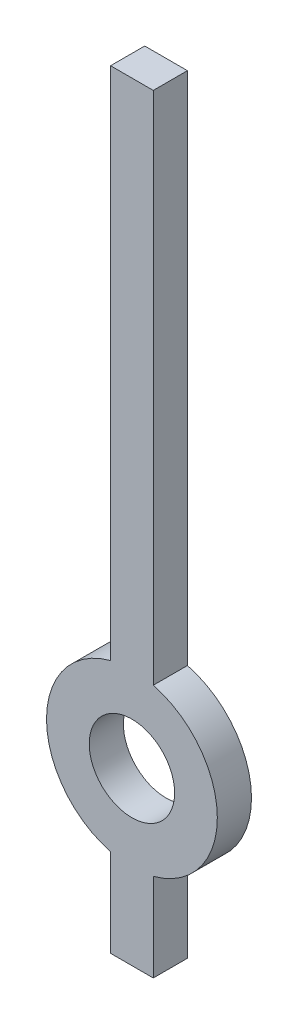
from build123d import *

# Parameters (mm, degrees)
CROQUIS1_R              = 0.25
SALIENTE_EXTRUIR1_DEPTH = 0.2


with BuildPart() as part:
    # Croquis1 → Saliente-Extruir1 (new body)
    with BuildSketch(Plane.XY):
        with BuildLine():
            Line((-0.125, -1), (-0.125, -0.484122918))
            ThreePointArc((-0.125, -0.484122918), (-0.5, 0), (-0.125, 0.484122918))
            Line((-0.125, 0.484122918), (-0.125, 3.5))
            Line((-0.125, 3.5), (0.125, 3.5))
            Line((0.125, 3.5), (0.125, 0.484122918))
            ThreePointArc((0.125, 0.484122918), (0.5, 0), (0.125, -0.484122918))
            Line((0.125, -0.484122918), (0.125, -1))
            Line((0.125, -1), (-0.125, -1))
        make_face()
        Circle(CROQUIS1_R, mode=Mode.SUBTRACT)
    extrude(amount=SALIENTE_EXTRUIR1_DEPTH)


solid = part.part
